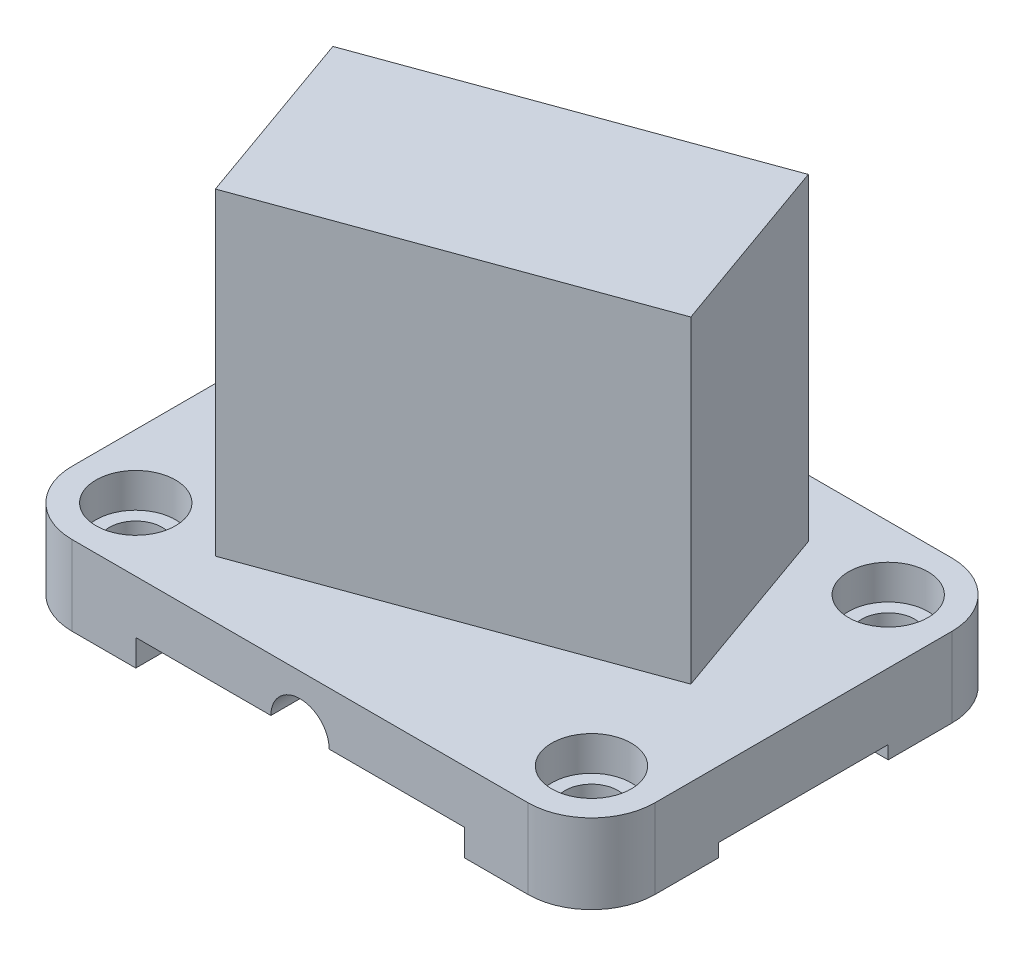
from build123d import *

# Parameters (mm, degrees)
BOSS_EXTRUDE1_DEPTH                      = 19.05
CBORE_FOR_1_2_HEX_HEAD_BOLT1_D           = 12.7
CBORE_FOR_1_2_HEX_HEAD_BOLT1_DEPTH       = 19.05
CBORE_FOR_1_2_HEX_HEAD_BOLT1_CBORE_D     = 19.05
CBORE_FOR_1_2_HEX_HEAD_BOLT1_CBORE_DEPTH = 8.255
CUT_EXTRUDE1_DEPTH                       = 102.6
SKETCH5_W                                = 40.64
SKETCH5_H                                = 3.175
CUT_EXTRUDE2_DEPTH                       = 140.7
BOSS_EXTRUDE2_DEPTH                      = 76.2


with BuildPart() as part:
    # Sketch1 → Boss-Extrude1 (new body)
    with BuildSketch(Plane(origin=(0, 0, 0), x_dir=(1, 0, 0), z_dir=(0, 1, 0))):
        with BuildLine():
            Line((-54.61, 50.8), (54.61, 50.8))
            ThreePointArc((54.61, 50.8), (65.386307345, 46.336307345), (69.85, 35.56))
            Line((69.85, 35.56), (69.85, -35.56))
            ThreePointArc((69.85, -35.56), (65.386307345, -46.336307345), (54.61, -50.8))
            Line((54.61, -50.8), (-54.61, -50.8))
            ThreePointArc((-54.61, -50.8), (-65.386307345, -46.336307345), (-69.85, -35.56))
            Line((-69.85, -35.56), (-69.85, 35.56))
            ThreePointArc((-69.85, 35.56), (-65.386307345, 46.336307345), (-54.61, 50.8))
        make_face()
    extrude(amount=BOSS_EXTRUDE1_DEPTH)

    # CBORE for 1/2 Hex Head Bolt1
    with Locations(Plane(origin=(0, 19.05, 0), x_dir=(1, 0, 0), z_dir=(0, 1, 0))):
        with Locations((-54.61, 35.56), (54.61, 35.56), (-54.61, -35.56), (54.61, -35.56)):
            CounterBoreHole(CBORE_FOR_1_2_HEX_HEAD_BOLT1_D / 2, CBORE_FOR_1_2_HEX_HEAD_BOLT1_CBORE_D / 2, CBORE_FOR_1_2_HEX_HEAD_BOLT1_CBORE_DEPTH, depth=CBORE_FOR_1_2_HEX_HEAD_BOLT1_DEPTH)

    # Sketch4 → Cut-Extrude1 (cut, through all)
    with BuildSketch(Plane.XY.offset(50.8)):
        with BuildLine():
            Line((-39.37, 0), (-39.37, 6.35))
            Line((-39.37, 6.35), (-6.985, 6.35))
            ThreePointArc((-6.985, 6.35), (0, 13.335), (6.985, 6.35))
            Line((6.985, 6.35), (39.37, 6.35))
            Line((39.37, 6.35), (39.37, 0))
            Line((39.37, 0), (-39.37, 0))
        make_face()
    extrude(amount=-CUT_EXTRUDE1_DEPTH, mode=Mode.SUBTRACT)

    # Sketch5 → Cut-Extrude2 (cut, through all)
    with BuildSketch(Plane.ZY.offset(69.85)):
        with Locations((0, 1.5875)):
            Rectangle(SKETCH5_W, SKETCH5_H)
    extrude(amount=-CUT_EXTRUDE2_DEPTH, mode=Mode.SUBTRACT)

    # Sketch6 → Boss-Extrude2 (add)
    with BuildSketch(Plane(origin=(0, 19.05, 0), x_dir=(1, 0, 0), z_dir=(0, 1, 0))):
        Polygon((-49.53, 6.604), (-34.008673988, -37.075222335), (49.53, -6.669631594), (34.008673988, 37.009590742), align=None)
    extrude(amount=BOSS_EXTRUDE2_DEPTH)


solid = part.part
